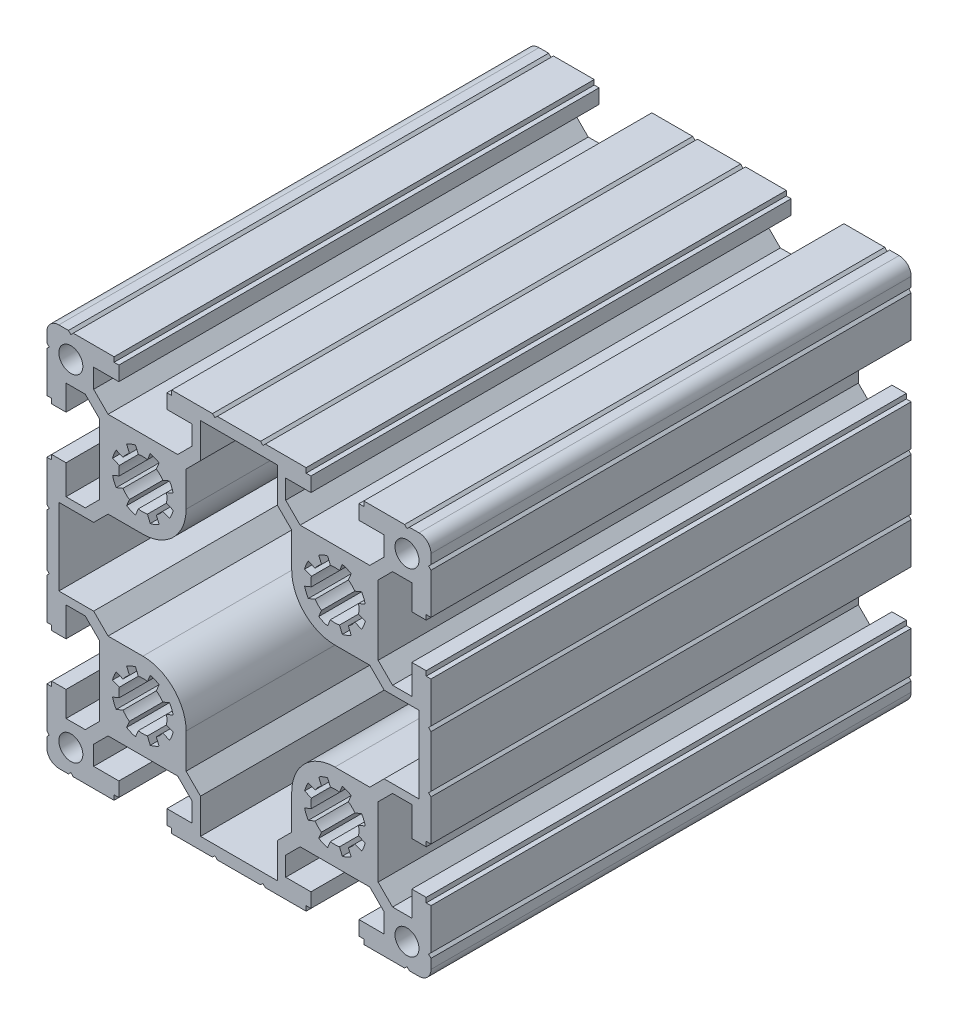
from build123d import *

# Parameters (mm, degrees)
IZIM1_R                     = 2.5
Y_KSEKLIK_EKSTR_ZYON1_DEPTH = 100


with BuildPart() as part:
    # Çizim1 → Yükseklik-Ekstrüzyon1 (new body)
    with BuildSketch(Plane.XY.offset(100)):
        with BuildLine():
            Line((32.00000152, 9.750000201), (28.999999166, 12.749999762))
            Line((28.999999166, 12.749999762), (28.999999166, 27.249999344))
            Line((28.999999166, 27.249999344), (32.00000152, 30.249999836))
            Line((32.00000152, 30.249999836), (35.99999845, 30.249999836))
            Line((35.99999845, 30.249999836), (35.99999845, 25.000000373))
            Line((35.99999845, 25.000000373), (39.000000805, 25.000000373))
            Line((39.000000805, 25.000000373), (39.000000805, 26.000000536))
            Line((39.000000805, 26.000000536), (39.999999106, 26.000000536))
            Line((39.999999106, 26.000000536), (39.999999106, 34.499999136))
            Line((39.999999106, 34.499999136), (39.499998093, 34.999996424))
            Line((39.499998093, 34.999996424), (39.999999106, 35.500001162))
            Line((39.999999106, 35.500001162), (39.999999106, 37.499999106))
            ThreePointArc((39.999999106, 37.499999106), (39.267766059, 39.267766059), (37.499999106, 39.999999106))
            Line((37.499999106, 39.999999106), (35.500001162, 39.999999106))
            Line((35.500001162, 39.999999106), (35.000003874, 39.499998093))
            Line((35.000003874, 39.499998093), (34.499999136, 39.999999106))
            Line((34.499999136, 39.999999106), (26.000000536, 39.999999106))
            Line((26.000000536, 39.999999106), (26.000000536, 39.000000805))
            Line((26.000000536, 39.000000805), (25.000000373, 39.000000805))
            Line((25.000000373, 39.000000805), (25.000000373, 35.99999845))
            Line((25.000000373, 35.99999845), (30.249999836, 35.99999845))
            Line((30.249999836, 35.99999845), (30.249999836, 32.00000152))
            Line((30.249999836, 32.00000152), (27.249999344, 28.999999166))
            Line((27.249999344, 28.999999166), (12.749999762, 28.999999166))
            Line((12.749999762, 28.999999166), (9.750000201, 32.00000152))
            Line((9.750000201, 32.00000152), (9.750000201, 35.99999845))
            Line((9.750000201, 35.99999845), (14.999999665, 35.99999845))
            Line((14.999999665, 35.99999845), (14.999999665, 39.000000805))
            Line((14.999999665, 39.000000805), (14.000000432, 39.000000805))
            Line((14.000000432, 39.000000805), (14.000000432, 39.999999106))
            Line((14.000000432, 39.999999106), (5.49999997, 39.999999106))
            Line((5.49999997, 39.999999106), (5.000002682, 39.499999024))
            Line((5.000002682, 39.499999024), (4.499999806, 39.999999106))
            Line((4.499999806, 39.999999106), (-4.499999806, 39.999999106))
            Line((-4.499999806, 39.999999106), (-4.999997094, 39.499999024))
            Line((-4.999997094, 39.499999024), (-5.49999997, 39.999999106))
            Line((-5.49999997, 39.999999106), (-14.000000432, 39.999999106))
            Line((-14.000000432, 39.999999106), (-14.000000432, 39.000000805))
            Line((-14.000000432, 39.000000805), (-14.999999665, 39.000000805))
            Line((-14.999999665, 39.000000805), (-14.999999665, 35.99999845))
            Line((-14.999999665, 35.99999845), (-9.750000201, 35.99999845))
            Line((-9.750000201, 35.99999845), (-9.750000201, 32.00000152))
            Line((-9.750000201, 32.00000152), (-12.749999762, 28.999999166))
            Line((-12.749999762, 28.999999166), (-27.249999344, 28.999999166))
            Line((-27.249999344, 28.999999166), (-30.249999836, 32.00000152))
            Line((-30.249999836, 32.00000152), (-30.249999836, 35.99999845))
            Line((-30.249999836, 35.99999845), (-25.000000373, 35.99999845))
            Line((-25.000000373, 35.99999845), (-25.000000373, 39.000000805))
            Line((-25.000000373, 39.000000805), (-26.000000536, 39.000000805))
            Line((-26.000000536, 39.000000805), (-26.000000536, 39.999999106))
            Line((-26.000000536, 39.999999106), (-34.499999136, 39.999999106))
            Line((-34.499999136, 39.999999106), (-34.999996424, 39.499998093))
            Line((-34.999996424, 39.499998093), (-35.500001162, 39.999999106))
            Line((-35.500001162, 39.999999106), (-37.499999106, 39.999999106))
            ThreePointArc((-37.499999106, 39.999999106), (-39.267766059, 39.267766059), (-39.999999106, 37.499999106))
            Line((-39.999999106, 37.499999106), (-39.999999106, 35.500001162))
            Line((-39.999999106, 35.500001162), (-39.499998093, 34.999996424))
            Line((-39.499998093, 34.999996424), (-39.999999106, 34.499999136))
            Line((-39.999999106, 34.499999136), (-39.999999106, 26.000000536))
            Line((-39.999999106, 26.000000536), (-39.000000805, 26.000000536))
            Line((-39.000000805, 26.000000536), (-39.000000805, 25.000000373))
            Line((-39.000000805, 25.000000373), (-35.99999845, 25.000000373))
            Line((-35.99999845, 25.000000373), (-35.99999845, 30.249999836))
            Line((-35.99999845, 30.249999836), (-32.00000152, 30.249999836))
            Line((-32.00000152, 30.249999836), (-28.999999166, 27.249999344))
            Line((-28.999999166, 27.249999344), (-28.999999166, 12.749999762))
            Line((-28.999999166, 12.749999762), (-32.00000152, 9.750000201))
            Line((-32.00000152, 9.750000201), (-35.99999845, 9.750000201))
            Line((-35.99999845, 9.750000201), (-35.99999845, 15.884915367))
            Line((-35.99999845, 15.884915367), (-39.000000805, 15.884915367))
            Line((-39.000000805, 15.884915367), (-39.000000805, 14.884915203))
            Line((-39.000000805, 14.884915203), (-39.999999106, 14.884915203))
            Line((-39.999999106, 14.884915203), (-39.999999106, 6.384915672))
            Line((-39.999999106, 6.384915672), (-39.499999024, 5.884912796))
            Line((-39.499999024, 5.884912796), (-39.999999106, 5.384915508))
            Line((-39.999999106, 5.384915508), (-39.999999106, -5.384915508))
            Line((-39.999999106, -5.384915508), (-39.499999024, -5.884918384))
            Line((-39.499999024, -5.884918384), (-39.999999106, -6.384915672))
            Line((-39.999999106, -6.384915672), (-39.999999106, -14.884915203))
            Line((-39.999999106, -14.884915203), (-39.000000805, -14.884915203))
            Line((-39.000000805, -14.884915203), (-39.000000805, -15.884915367))
            Line((-39.000000805, -15.884915367), (-35.99999845, -15.884915367))
            Line((-35.99999845, -15.884915367), (-35.99999845, -9.750000201))
            Line((-35.99999845, -9.750000201), (-32.00000152, -9.750000201))
            Line((-32.00000152, -9.750000201), (-28.999999166, -12.749999762))
            Line((-28.999999166, -12.749999762), (-28.999999166, -27.249999344))
            Line((-28.999999166, -27.249999344), (-32.00000152, -30.249999836))
            Line((-32.00000152, -30.249999836), (-35.99999845, -30.249999836))
            Line((-35.99999845, -30.249999836), (-35.99999845, -25.000000373))
            Line((-35.99999845, -25.000000373), (-39.000000805, -25.000000373))
            Line((-39.000000805, -25.000000373), (-39.000000805, -26.000000536))
            Line((-39.000000805, -26.000000536), (-39.999999106, -26.000000536))
            Line((-39.999999106, -26.000000536), (-39.999999106, -34.499999136))
            Line((-39.999999106, -34.499999136), (-39.499998093, -35.000003874))
            Line((-39.499998093, -35.000003874), (-39.999999106, -35.500001162))
            Line((-39.999999106, -35.500001162), (-39.999999106, -37.499999106))
            ThreePointArc((-39.999999106, -37.499999106), (-39.267766059, -39.267766059), (-37.499999106, -39.999999106))
            Line((-37.499999106, -39.999999106), (-35.500001162, -39.999999106))
            Line((-35.500001162, -39.999999106), (-34.999996424, -39.499998093))
            Line((-34.999996424, -39.499998093), (-34.499999136, -39.999999106))
            Line((-34.499999136, -39.999999106), (-26.000000536, -39.999999106))
            Line((-26.000000536, -39.999999106), (-26.000000536, -39.000000805))
            Line((-26.000000536, -39.000000805), (-25.000000373, -39.000000805))
            Line((-25.000000373, -39.000000805), (-25.000000373, -35.99999845))
            Line((-25.000000373, -35.99999845), (-30.249999836, -35.99999845))
            Line((-30.249999836, -35.99999845), (-30.249999836, -32.00000152))
            Line((-30.249999836, -32.00000152), (-27.249999344, -28.999999166))
            Line((-27.249999344, -28.999999166), (-12.749999762, -28.999999166))
            Line((-12.749999762, -28.999999166), (-9.750000201, -32.00000152))
            Line((-9.750000201, -32.00000152), (-9.750000201, -35.99999845))
            Line((-9.750000201, -35.99999845), (-14.999999665, -35.99999845))
            Line((-14.999999665, -35.99999845), (-14.999999665, -39.000000805))
            Line((-14.999999665, -39.000000805), (-14.000000432, -39.000000805))
            Line((-14.000000432, -39.000000805), (-14.000000432, -39.999999106))
            Line((-14.000000432, -39.999999106), (-5.49999997, -39.999999106))
            Line((-5.49999997, -39.999999106), (-4.999997094, -39.499999024))
            Line((-4.999997094, -39.499999024), (-4.499999806, -39.999999106))
            Line((-4.499999806, -39.999999106), (4.499999806, -39.999999106))
            Line((4.499999806, -39.999999106), (5.000002682, -39.499999024))
            Line((5.000002682, -39.499999024), (5.49999997, -39.999999106))
            Line((5.49999997, -39.999999106), (14.000000432, -39.999999106))
            Line((14.000000432, -39.999999106), (14.000000432, -39.000000805))
            Line((14.000000432, -39.000000805), (14.999999665, -39.000000805))
            Line((14.999999665, -39.000000805), (14.999999665, -35.99999845))
            Line((14.999999665, -35.99999845), (9.750000201, -35.99999845))
            Line((9.750000201, -35.99999845), (9.750000201, -32.00000152))
            Line((9.750000201, -32.00000152), (12.749999762, -28.999999166))
            Line((12.749999762, -28.999999166), (27.249999344, -28.999999166))
            Line((27.249999344, -28.999999166), (30.249999836, -32.00000152))
            Line((30.249999836, -32.00000152), (30.249999836, -35.99999845))
            Line((30.249999836, -35.99999845), (25.000000373, -35.99999845))
            Line((25.000000373, -35.99999845), (25.000000373, -39.000000805))
            Line((25.000000373, -39.000000805), (26.000000536, -39.000000805))
            Line((26.000000536, -39.000000805), (26.000000536, -39.999999106))
            Line((26.000000536, -39.999999106), (34.499999136, -39.999999106))
            Line((34.499999136, -39.999999106), (35.000003874, -39.499998093))
            Line((35.000003874, -39.499998093), (35.500001162, -39.999999106))
            Line((35.500001162, -39.999999106), (37.499999106, -39.999999106))
            ThreePointArc((37.499999106, -39.999999106), (39.267766059, -39.267766059), (39.999999106, -37.499999106))
            Line((39.999999106, -37.499999106), (39.999999106, -35.500001162))
            Line((39.999999106, -35.500001162), (39.499998093, -35.000003874))
            Line((39.499998093, -35.000003874), (39.999999106, -34.499999136))
            Line((39.999999106, -34.499999136), (39.999999106, -26.000000536))
            Line((39.999999106, -26.000000536), (39.000000805, -26.000000536))
            Line((39.000000805, -26.000000536), (39.000000805, -25.000000373))
            Line((39.000000805, -25.000000373), (35.99999845, -25.000000373))
            Line((35.99999845, -25.000000373), (35.99999845, -30.249999836))
            Line((35.99999845, -30.249999836), (32.00000152, -30.249999836))
            Line((32.00000152, -30.249999836), (28.999999166, -27.249999344))
            Line((28.999999166, -27.249999344), (28.999999166, -12.749999762))
            Line((28.999999166, -12.749999762), (32.00000152, -9.750000201))
            Line((32.00000152, -9.750000201), (35.99999845, -9.750000201))
            Line((35.99999845, -9.750000201), (35.99999845, -15.884915367))
            Line((35.99999845, -15.884915367), (39.000000805, -15.884915367))
            Line((39.000000805, -15.884915367), (39.000000805, -14.884915203))
            Line((39.000000805, -14.884915203), (39.999999106, -14.884915203))
            Line((39.999999106, -14.884915203), (39.999999106, -6.384915672))
            Line((39.999999106, -6.384915672), (39.499999024, -5.884918384))
            Line((39.499999024, -5.884918384), (39.999999106, -5.384915508))
            Line((39.999999106, -5.384915508), (39.999999106, 5.384915508))
            Line((39.999999106, 5.384915508), (39.499999024, 5.884912796))
            Line((39.499999024, 5.884912796), (39.999999106, 6.384915672))
            Line((39.999999106, 6.384915672), (39.999999106, 14.884915203))
            Line((39.999999106, 14.884915203), (39.000000805, 14.884915203))
            Line((39.000000805, 14.884915203), (39.000000805, 15.884915367))
            Line((39.000000805, 15.884915367), (35.99999845, 15.884915367))
            Line((35.99999845, 15.884915367), (35.99999845, 9.750000201))
            Line((35.99999845, 9.750000201), (32.00000152, 9.750000201))
        make_face()
        with Locations((35, 35)):
            Circle(IZIM1_R, mode=Mode.SUBTRACT)
        with Locations((35, -35)):
            Circle(IZIM1_R, mode=Mode.SUBTRACT)
        with Locations((-35, 35)):
            Circle(IZIM1_R, mode=Mode.SUBTRACT)
        with Locations((-35, -35)):
            Circle(IZIM1_R, mode=Mode.SUBTRACT)
        with BuildLine():
            Line((15.091249512, -19.049118972), (13.683592519, -18.466048428))
            ThreePointArc((13.683592519, -18.466048428), (13.994782611, -17.512555559), (14.448959113, -16.618289586))
            Line((14.448959113, -16.618289586), (15.856616085, -17.201360122))
            ThreePointArc((15.856616085, -17.201360122), (16.464465975, -16.464463512), (17.201362584, -15.856613622))
            Line((17.201362584, -15.856613622), (16.618292049, -14.448956651))
            ThreePointArc((16.618292049, -14.448956651), (17.512558022, -13.994780148), (18.466050891, -13.683590057))
            Line((18.466050891, -13.683590057), (19.049121435, -15.091247049))
            ThreePointArc((19.049121435, -15.091247049), (20.000000302, -14.999997418), (20.950879154, -15.09124721))
            Line((20.950879154, -15.09124721), (21.533949683, -13.683590254))
            ThreePointArc((21.533949683, -13.683590254), (22.487442512, -13.994780468), (23.381708426, -14.448957086))
            Line((23.381708426, -14.448957086), (22.798637876, -15.856614094))
            ThreePointArc((22.798637876, -15.856614094), (23.535534208, -16.464463934), (24.143383872, -17.201360411))
            Line((24.143383872, -17.201360411), (25.551040828, -16.618289882))
            ThreePointArc((25.551040828, -16.618289882), (26.005217283, -17.512555879), (26.316407324, -18.466048765))
            Line((26.316407324, -18.466048765), (24.908750316, -19.049119315))
            ThreePointArc((24.908750316, -19.049119315), (24.999999881, -19.99999784), (24.908750155, -20.950876349))
            Line((24.908750155, -20.950876349), (26.316407127, -21.533946884))
            ThreePointArc((26.316407127, -21.533946884), (26.005216963, -22.48743973), (25.551040393, -23.381705668))
            Line((25.551040393, -23.381705668), (24.143383401, -22.798635124))
            ThreePointArc((24.143383401, -22.798635124), (23.535533787, -23.535531324), (22.798637587, -24.143380938))
            Line((22.798637587, -24.143380938), (23.381708131, -25.551037931))
            ThreePointArc((23.381708131, -25.551037931), (22.487442192, -26.0052145), (21.533949346, -26.316404664))
            Line((21.533949346, -26.316404664), (20.950878811, -24.908747693))
            ThreePointArc((20.950878811, -24.908747693), (20.000000302, -24.999997418), (19.049121778, -24.908747853))
            Line((19.049121778, -24.908747853), (18.466051228, -26.316404861))
            ThreePointArc((18.466051228, -26.316404861), (17.512558342, -26.00521482), (16.618292345, -25.551038366))
            Line((16.618292345, -25.551038366), (17.201362874, -24.14338141))
            ThreePointArc((17.201362874, -24.14338141), (16.464466396, -23.535531746), (15.856616556, -22.798635413))
            Line((15.856616556, -22.798635413), (14.448959548, -23.381705964))
            ThreePointArc((14.448959548, -23.381705964), (13.994782931, -22.487440049), (13.683592717, -21.53394722))
            Line((13.683592717, -21.53394722), (15.091249672, -20.950876691))
            ThreePointArc((15.091249672, -20.950876691), (14.999999881, -19.99999784), (15.091249512, -19.049118972))
        make_face(mode=Mode.SUBTRACT)
        with BuildLine():
            Line((-24.908750369, -19.049118972), (-26.316407361, -18.466048428))
            ThreePointArc((-26.316407361, -18.466048428), (-26.00521727, -17.512555559), (-25.551040767, -16.618289586))
            Line((-25.551040767, -16.618289586), (-24.143383796, -17.201360122))
            ThreePointArc((-24.143383796, -17.201360122), (-23.535533906, -16.464463512), (-22.798637297, -15.856613622))
            Line((-22.798637297, -15.856613622), (-23.381707832, -14.448956651))
            ThreePointArc((-23.381707832, -14.448956651), (-22.487441859, -13.994780148), (-21.53394899, -13.683590057))
            Line((-21.53394899, -13.683590057), (-20.950878446, -15.091247049))
            ThreePointArc((-20.950878446, -15.091247049), (-19.999999578, -14.999997418), (-19.049120727, -15.09124721))
            Line((-19.049120727, -15.09124721), (-18.466050198, -13.683590254))
            ThreePointArc((-18.466050198, -13.683590254), (-17.512557369, -13.994780468), (-16.618291455, -14.448957086))
            Line((-16.618291455, -14.448957086), (-17.201362005, -15.856614094))
            ThreePointArc((-17.201362005, -15.856614094), (-16.464465673, -16.464463934), (-15.856616008, -17.201360411))
            Line((-15.856616008, -17.201360411), (-14.448959052, -16.618289882))
            ThreePointArc((-14.448959052, -16.618289882), (-13.994782598, -17.512555879), (-13.683592557, -18.466048765))
            Line((-13.683592557, -18.466048765), (-15.091249565, -19.049119315))
            ThreePointArc((-15.091249565, -19.049119315), (-15, -19.99999784), (-15.091249725, -20.950876349))
            Line((-15.091249725, -20.950876349), (-13.683592754, -21.533946884))
            ThreePointArc((-13.683592754, -21.533946884), (-13.994782918, -22.48743973), (-14.448959487, -23.381705668))
            Line((-14.448959487, -23.381705668), (-15.85661648, -22.798635124))
            ThreePointArc((-15.85661648, -22.798635124), (-16.464466094, -23.535531324), (-17.201362294, -24.143380938))
            Line((-17.201362294, -24.143380938), (-16.61829175, -25.551037931))
            ThreePointArc((-16.61829175, -25.551037931), (-17.512557689, -26.0052145), (-18.466050534, -26.316404664))
            Line((-18.466050534, -26.316404664), (-19.049121069, -24.908747693))
            ThreePointArc((-19.049121069, -24.908747693), (-19.999999578, -24.999997418), (-20.950878103, -24.908747853))
            Line((-20.950878103, -24.908747853), (-21.533948653, -26.316404861))
            ThreePointArc((-21.533948653, -26.316404861), (-22.487441539, -26.00521482), (-23.381707536, -25.551038366))
            Line((-23.381707536, -25.551038366), (-22.798637007, -24.14338141))
            ThreePointArc((-22.798637007, -24.14338141), (-23.535533484, -23.535531746), (-24.143383324, -22.798635413))
            Line((-24.143383324, -22.798635413), (-25.551040332, -23.381705964))
            ThreePointArc((-25.551040332, -23.381705964), (-26.00521695, -22.487440049), (-26.316407164, -21.53394722))
            Line((-26.316407164, -21.53394722), (-24.908750208, -20.950876691))
            ThreePointArc((-24.908750208, -20.950876691), (-25, -19.99999784), (-24.908750369, -19.049118972))
        make_face(mode=Mode.SUBTRACT)
        with BuildLine():
            Line((-30.249996442, -7.999996926), (-37.499998096, -7.999996926))
            Line((-37.499998096, -7.999996926), (-37.499998096, 7.999996926))
            Line((-37.499998096, 7.999996926), (-30.249996442, 7.999996926))
            Line((-30.249996442, 7.999996926), (-27.249996882, 10.999997418))
            Line((-27.249996882, 10.999997418), (-20, 10.999997418))
            ThreePointArc((-20, 10.999997418), (-13.636038969, 13.636036387), (-11, 19.999997418))
            Line((-11, 19.999997418), (-11, 27.249999344))
            Line((-11, 27.249999344), (-8.00000044, 30.249999836))
            Line((-8.00000044, 30.249999836), (-8.00000044, 37.50000149))
            Line((-8.00000044, 37.50000149), (7.999999389, 37.50000149))
            Line((7.999999389, 37.50000149), (7.999999389, 30.250005812))
            Line((7.999999389, 30.250005812), (10.999999881, 27.250004389))
            Line((10.999999881, 27.250004389), (10.999999881, 19.999997418))
            ThreePointArc((10.999999881, 19.999997418), (13.63603885, 13.636036387), (19.999999881, 10.999997418))
            Line((19.999999881, 10.999997418), (27.250001807, 10.999997418))
            Line((27.250001807, 10.999997418), (30.250001367, 7.999996926))
            Line((30.250001367, 7.999996926), (37.500004884, 7.999996926))
            Line((37.500004884, 7.999996926), (37.500004884, -7.999996926))
            Line((37.500004884, -7.999996926), (30.25000323, -7.999996926))
            Line((30.25000323, -7.999996926), (27.250001807, -10.999997418))
            Line((27.250001807, -10.999997418), (19.999999881, -10.999997418))
            ThreePointArc((19.999999881, -10.999997418), (13.63603885, -13.636036387), (10.999999881, -19.999997418))
            Line((10.999999881, -19.999997418), (10.999999881, -27.2499943))
            Line((10.999999881, -27.2499943), (7.999999389, -30.24999386))
            Line((7.999999389, -30.24999386), (7.999999389, -37.50000149))
            Line((7.999999389, -37.50000149), (-8.00000044, -37.50000149))
            Line((-8.00000044, -37.50000149), (-8.00000044, -30.249999836))
            Line((-8.00000044, -30.249999836), (-11, -27.249999344))
            Line((-11, -27.249999344), (-11, -19.999997418))
            ThreePointArc((-11, -19.999997418), (-13.636038969, -13.636036387), (-20, -10.999997418))
            Line((-20, -10.999997418), (-27.249996882, -10.999997418))
            Line((-27.249996882, -10.999997418), (-30.249996442, -7.999996926))
        make_face(mode=Mode.SUBTRACT)
        with BuildLine():
            Line((-24.908750369, 20.950875864), (-26.316407361, 21.533946408))
            ThreePointArc((-26.316407361, 21.533946408), (-26.00521727, 22.487439277), (-25.551040767, 23.38170525))
            Line((-25.551040767, 23.38170525), (-24.143383796, 22.798634715))
            ThreePointArc((-24.143383796, 22.798634715), (-23.535533906, 23.535531324), (-22.798637297, 24.143381214))
            Line((-22.798637297, 24.143381214), (-23.381707832, 25.551038185))
            ThreePointArc((-23.381707832, 25.551038185), (-22.487441859, 26.005214688), (-21.53394899, 26.31640478))
            Line((-21.53394899, 26.31640478), (-20.950878446, 24.908747787))
            ThreePointArc((-20.950878446, 24.908747787), (-19.999999578, 24.999997418), (-19.049120727, 24.908747626))
            Line((-19.049120727, 24.908747626), (-18.466050198, 26.316404582))
            ThreePointArc((-18.466050198, 26.316404582), (-17.512557369, 26.005214368), (-16.618291455, 25.551037751))
            Line((-16.618291455, 25.551037751), (-17.201362005, 24.143380742))
            ThreePointArc((-17.201362005, 24.143380742), (-16.464465673, 23.535530902), (-15.856616008, 22.798634425))
            Line((-15.856616008, 22.798634425), (-14.448959052, 23.381704954))
            ThreePointArc((-14.448959052, 23.381704954), (-13.994782598, 22.487438957), (-13.683592557, 21.533946071))
            Line((-13.683592557, 21.533946071), (-15.091249565, 20.950875521))
            ThreePointArc((-15.091249565, 20.950875521), (-15, 19.999996997), (-15.091249725, 19.049118487))
            Line((-15.091249725, 19.049118487), (-13.683592754, 18.466047952))
            ThreePointArc((-13.683592754, 18.466047952), (-13.994782918, 17.512555107), (-14.448959487, 16.618289168))
            Line((-14.448959487, 16.618289168), (-15.85661648, 17.201359712))
            ThreePointArc((-15.85661648, 17.201359712), (-16.464466094, 16.464463512), (-17.201362294, 15.856613898))
            Line((-17.201362294, 15.856613898), (-16.61829175, 14.448956905))
            ThreePointArc((-16.61829175, 14.448956905), (-17.512557689, 13.994780336), (-18.466050534, 13.683590172))
            Line((-18.466050534, 13.683590172), (-19.049121069, 15.091247143))
            ThreePointArc((-19.049121069, 15.091247143), (-19.999999578, 14.999997418), (-20.950878103, 15.091246983))
            Line((-20.950878103, 15.091246983), (-21.533948653, 13.683589975))
            ThreePointArc((-21.533948653, 13.683589975), (-22.487441539, 13.994780016), (-23.381707536, 14.448956471))
            Line((-23.381707536, 14.448956471), (-22.798637007, 15.856613426))
            ThreePointArc((-22.798637007, 15.856613426), (-23.535533484, 16.464463091), (-24.143383324, 17.201359423))
            Line((-24.143383324, 17.201359423), (-25.551040332, 16.618288873))
            ThreePointArc((-25.551040332, 16.618288873), (-26.00521695, 17.512554787), (-26.316407164, 18.466047616))
            Line((-26.316407164, 18.466047616), (-24.908750208, 19.049118145))
            ThreePointArc((-24.908750208, 19.049118145), (-25, 19.999996997), (-24.908750369, 20.950875864))
        make_face(mode=Mode.SUBTRACT)
        with BuildLine():
            Line((15.091249512, 20.950875864), (13.683592519, 21.533946408))
            ThreePointArc((13.683592519, 21.533946408), (13.994782611, 22.487439277), (14.448959113, 23.38170525))
            Line((14.448959113, 23.38170525), (15.856616085, 22.798634715))
            ThreePointArc((15.856616085, 22.798634715), (16.464465975, 23.535531324), (17.201362584, 24.143381214))
            Line((17.201362584, 24.143381214), (16.618292049, 25.551038185))
            ThreePointArc((16.618292049, 25.551038185), (17.512558022, 26.005214688), (18.466050891, 26.31640478))
            Line((18.466050891, 26.31640478), (19.049121435, 24.908747787))
            ThreePointArc((19.049121435, 24.908747787), (20.000000302, 24.999997418), (20.950879154, 24.908747626))
            Line((20.950879154, 24.908747626), (21.533949683, 26.316404582))
            ThreePointArc((21.533949683, 26.316404582), (22.487442512, 26.005214368), (23.381708426, 25.551037751))
            Line((23.381708426, 25.551037751), (22.798637876, 24.143380742))
            ThreePointArc((22.798637876, 24.143380742), (23.535534208, 23.535530902), (24.143383872, 22.798634425))
            Line((24.143383872, 22.798634425), (25.551040828, 23.381704954))
            ThreePointArc((25.551040828, 23.381704954), (26.005217283, 22.487438957), (26.316407324, 21.533946071))
            Line((26.316407324, 21.533946071), (24.908750316, 20.950875521))
            ThreePointArc((24.908750316, 20.950875521), (24.999999881, 19.999996997), (24.908750155, 19.049118487))
            Line((24.908750155, 19.049118487), (26.316407127, 18.466047952))
            ThreePointArc((26.316407127, 18.466047952), (26.005216963, 17.512555107), (25.551040393, 16.618289168))
            Line((25.551040393, 16.618289168), (24.143383401, 17.201359712))
            ThreePointArc((24.143383401, 17.201359712), (23.535533787, 16.464463512), (22.798637587, 15.856613898))
            Line((22.798637587, 15.856613898), (23.381708131, 14.448956905))
            ThreePointArc((23.381708131, 14.448956905), (22.487442192, 13.994780336), (21.533949346, 13.683590172))
            Line((21.533949346, 13.683590172), (20.950878811, 15.091247143))
            ThreePointArc((20.950878811, 15.091247143), (20.000000302, 14.999997418), (19.049121778, 15.091246983))
            Line((19.049121778, 15.091246983), (18.466051228, 13.683589975))
            ThreePointArc((18.466051228, 13.683589975), (17.512558342, 13.994780016), (16.618292345, 14.448956471))
            Line((16.618292345, 14.448956471), (17.201362874, 15.856613426))
            ThreePointArc((17.201362874, 15.856613426), (16.464466396, 16.464463091), (15.856616556, 17.201359423))
            Line((15.856616556, 17.201359423), (14.448959548, 16.618288873))
            ThreePointArc((14.448959548, 16.618288873), (13.994782931, 17.512554787), (13.683592717, 18.466047616))
            Line((13.683592717, 18.466047616), (15.091249672, 19.049118145))
            ThreePointArc((15.091249672, 19.049118145), (14.999999881, 19.999996997), (15.091249512, 20.950875864))
        make_face(mode=Mode.SUBTRACT)
    extrude(amount=-Y_KSEKLIK_EKSTR_ZYON1_DEPTH)


solid = part.part
